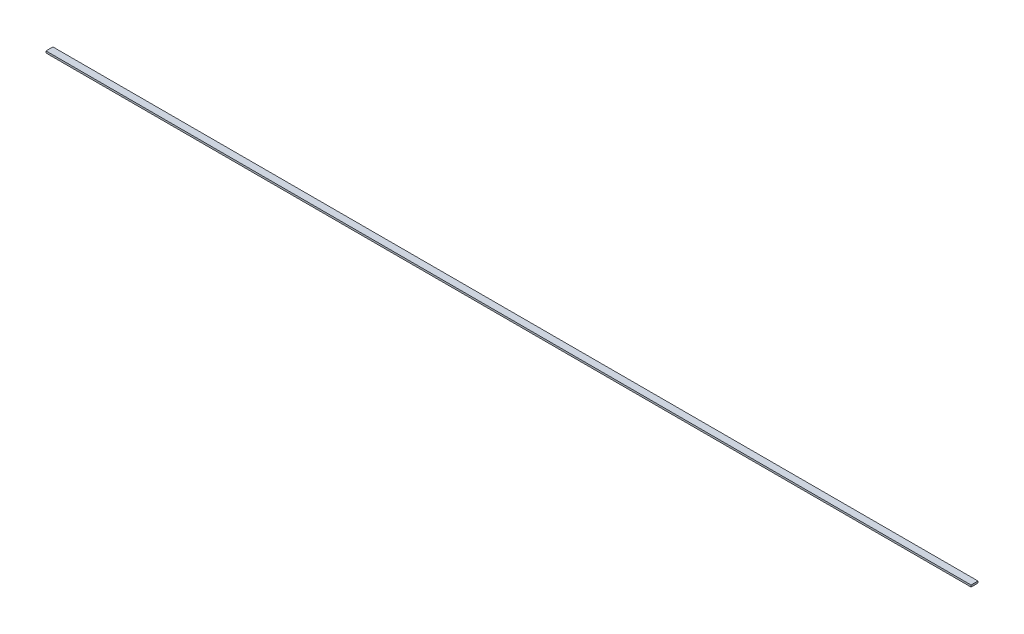
from build123d import *

# Parameters (mm, degrees)
SKETCH_1_W      = 550
SKETCH_1_H      = 4.125
EXTRUDE_1_DEPTH = 1.09


with BuildPart() as part:
    # Эскиз1 → Бобышка-Вытянуть1 (new body)
    with BuildSketch(Plane.XZ.offset(0.545)):
        with Locations((0, 2.0625)):
            Rectangle(SKETCH_1_W, SKETCH_1_H)
    extrude(amount=-EXTRUDE_1_DEPTH)


solid = part.part
